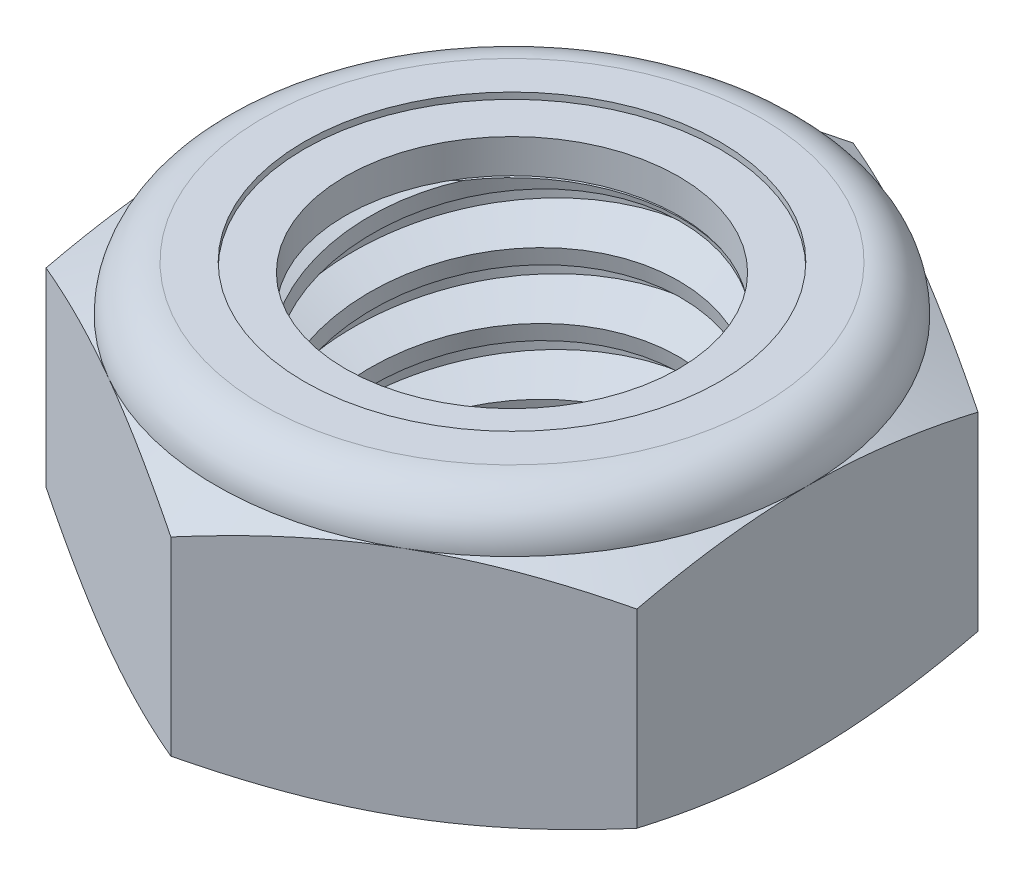
from build123d import *

# Parameters (mm, degrees)
EXTRUDE1_DEPTH      = 6.746875
SKETCH2_W           = 4.7625
SKETCH2_H           = 6.746875
LPATTERN1_COUNT     = 4
LPATTERN1_PITCH     = 1.5875
LPATTERN1_COL_COUNT = 2
LPATTERN1_COL_PITCH = 1.5875


with BuildPart() as part:
    # Sketch1 → Extrude1 (new body)
    with BuildSketch(Plane(origin=(0, 0, 0), x_dir=(1, 0, 0), z_dir=(0, 1, 0))):
        Polygon((0, 8.248891971), (-7.14375, 4.124445986), (-7.14375, -4.124445986), (0, -8.248891971), (7.14375, -4.124445986), (7.14375, 4.124445986), align=None)
    extrude(amount=EXTRUDE1_DEPTH)

    # Sketch4 → Cut-Revolve2 (revolve, cut)
    with BuildSketch(Plane(origin=(0, 0, 0), x_dir=(0, 0, -1), z_dir=(1, 0, 0))):
        Polygon((0, 6.746875), (4.7625, 6.746875), (4.029111805, 6.404890468), (4.029111805, 0.341984532), (4.7625, 0), (0, 0), align=None)
    revolve(axis=Axis((0, 6.746875, 0), (0, 1, 0)), mode=Mode.SUBTRACT)


with BuildPart() as body_2:
    # Sketch2 → Revolve1 (revolve)
    with BuildSketch(Plane(origin=(0, 0, 0), x_dir=(0, 0, -1), z_dir=(1, 0, 0))):
        with Locations((2.38125, 3.3734375)):
            Rectangle(SKETCH2_W, SKETCH2_H)
    revolve(axis=Axis((0, -4.7625, 0), (0, 1, 0)))

    # Sketch3 → Cut-Revolve1 (revolve, cut)
    with BuildSketch(Plane(origin=(0, 0, 0), x_dir=(0, 0, -1), z_dir=(1, 0, 0))):
        Polygon((4.795122924, 6.551137456), (5.023483392, 5.180974646), (4.094357653, 5.529057102), (4.029111805, 5.92053219), align=None)
    cut_revolve1 = revolve(axis=Axis((0, 6.746875, 0.28317269), (0, -0.986393924, -0.164398987)), mode=Mode.SUBTRACT)

    # LPattern1: Cut-Revolve1 ×4
    with Locations(*[(0, -i * LPATTERN1_PITCH, 0) for i in range(1, LPATTERN1_COUNT)]):
        add(cut_revolve1, mode=Mode.SUBTRACT)

    # LPattern1 col: Cut-Revolve1 ×2
    with Locations(*[(0, i * LPATTERN1_COL_PITCH, 0) for i in range(1, LPATTERN1_COL_COUNT)]):
        add(cut_revolve1, mode=Mode.SUBTRACT)


with BuildPart() as part_1:
    add(part.part)

    # Combine1: cut body 2
    add(body_2.part, mode=Mode.SUBTRACT)

    # Sketch5 → Cut-Revolve3 (revolve, cut)
    with BuildSketch(Plane(origin=(0, 0, 0), x_dir=(0, 0, -1), z_dir=(1, 0, 0))):
        with BuildLine():
            Line((0, 0), (7.14375, 0))
            Line((7.14375, 0), (8.248891971, 0.515336164))
            Line((8.248891971, 0.515336164), (8.248891971, 5.107059669))
            Line((8.248891971, 5.107059669), (7.14375, 5.622395833))
            ThreePointArc((7.14375, 5.622395833), (6.814397677, 6.417522677), (6.019270833, 6.746875))
            Line((6.019270833, 6.746875), (6.019270833, 8.016875))
            Line((6.019270833, 8.016875), (9.518891971, 8.016875))
            Line((9.518891971, 8.016875), (9.518891971, -1.27))
            Line((9.518891971, -1.27), (0, -1.27))
            Line((0, -1.27), (0, 0))
        make_face()
    revolve(axis=Axis((0, 0, 0), (0, 1, 0)), mode=Mode.SUBTRACT)

    # Sketch6 → Cut-Revolve4 (revolve, cut)
    with BuildSketch(Plane(origin=(0, 0, 0), x_dir=(0, 0, -1), z_dir=(1, 0, 0))):
        with BuildLine():
            Line((0, 5.622395833), (6.99135, 5.622395833))
            ThreePointArc((6.99135, 5.622395833), (6.706634604, 6.309759604), (6.019270833, 6.594475))
            Line((6.019270833, 6.594475), (5.024191319, 6.594475))
            Line((5.024191319, 6.594475), (5.024191319, 8.016875))
            Line((5.024191319, 8.016875), (0, 8.016875))
            Line((0, 8.016875), (0, 5.622395833))
        make_face()
    revolve(axis=Axis((0, 8.016875, 0), (0, 1, 0)), mode=Mode.SUBTRACT)


with BuildPart() as body_2_2:
    # Sketch7 → Revolve2 (revolve)
    with BuildSketch(Plane(origin=(0, 0, 0), x_dir=(0, 0, -1), z_dir=(1, 0, 0))):
        with BuildLine():
            Line((4.029111805, 5.698595833), (6.91190348, 5.698595833))
            ThreePointArc((6.91190348, 5.698595833), (6.625213689, 6.282269107), (6.019270833, 6.518275))
            Line((6.019270833, 6.518275), (4.029111805, 6.518275))
            Line((4.029111805, 6.518275), (4.029111805, 5.698595833))
        make_face()
    revolve(axis=Axis((0, 5.698595833, 0), (0, 1, 0)))


solid = Compound([part_1.part, body_2_2.part])
